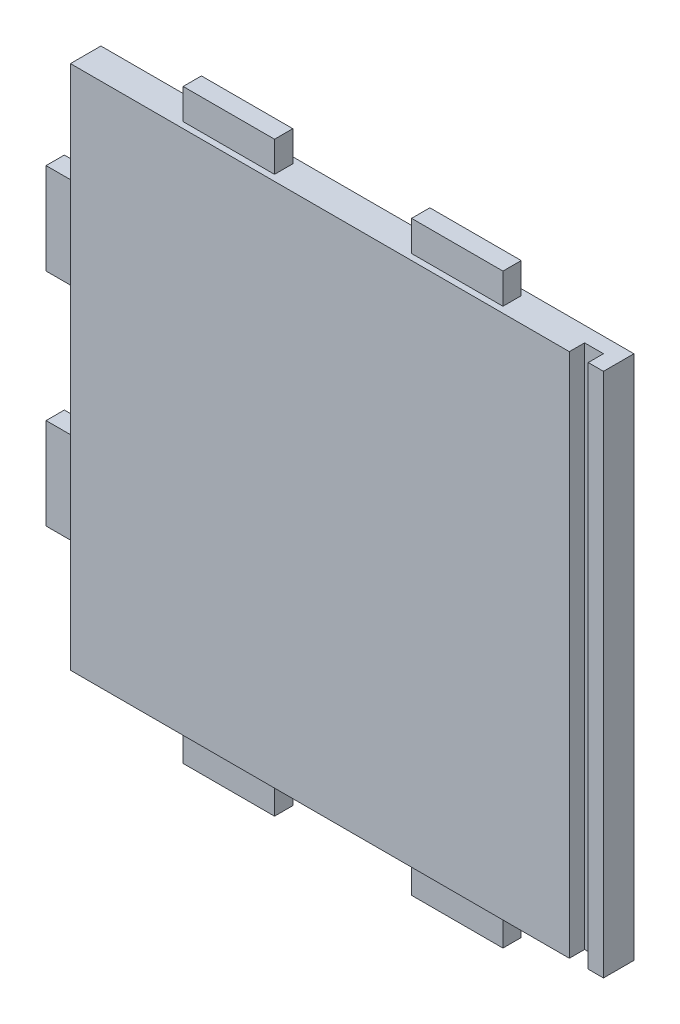
from build123d import *

# Parameters (mm, degrees)
ESBO_O1_W                = 175
ESBO_O1_H                = 172.5
RESSALTO_EXTRUS_O1_DEPTH = 10
ESBO_O5_W                = 30
ESBO_O5_H                = 6
RESSALTO_EXTRUS_O5_DEPTH = 10
ESBO_O6_W                = 6
ESBO_O6_H                = 30
RESSALTO_EXTRUS_O6_DEPTH = 10
ESBO_O7_W                = 30
ESBO_O7_H                = 6
RESSALTO_EXTRUS_O7_DEPTH = 10
ESBO_O9_W                = 6.2
ESBO_O9_H                = 172.5
CORTE_EXTRUS_O2_DEPTH    = 5
ESBO_O10_R               = 1.5
CORTE_EXTRUS_O3_DEPTH    = 8
ESBO_O11_R               = 1.5
CORTE_EXTRUS_O4_DEPTH    = 8


with BuildPart() as part:
    # Esboço1 → Ressalto-extrusão1 (new body)
    with BuildSketch(Plane.XY):
        Rectangle(ESBO_O1_W, ESBO_O1_H)
    extrude(amount=RESSALTO_EXTRUS_O1_DEPTH)

    # Esboço5 → Ressalto-extrusão5 (add)
    with BuildSketch(Plane(origin=(0, 86.25, 0), x_dir=(1, 0, 0), z_dir=(0, 1, 0))):
        with Locations((-37.5, -5)):
            Rectangle(ESBO_O5_W, ESBO_O5_H)
        with Locations((37.5, -5)):
            Rectangle(ESBO_O5_W, ESBO_O5_H)
    extrude(amount=RESSALTO_EXTRUS_O5_DEPTH)

    # Esboço6 → Ressalto-extrusão6 (add)
    with BuildSketch(Plane.ZY.offset(87.5)):
        with Locations((5, 36.25)):
            Rectangle(ESBO_O6_W, ESBO_O6_H)
        with Locations((5, -36.25)):
            Rectangle(ESBO_O6_W, ESBO_O6_H)
    extrude(amount=RESSALTO_EXTRUS_O6_DEPTH)

    # Esboço7 → Ressalto-extrusão7 (add)
    with BuildSketch(Plane.XZ.offset(86.25)):
        with Locations((-37.5, 5)):
            Rectangle(ESBO_O7_W, ESBO_O7_H)
        with Locations((37.5, 5)):
            Rectangle(ESBO_O7_W, ESBO_O7_H)
    extrude(amount=RESSALTO_EXTRUS_O7_DEPTH)

    # Esboço9 → Corte-extrusão2 (cut)
    with BuildSketch(Plane.XY.offset(10)):
        with Locations((79.4, 0)):
            Rectangle(ESBO_O9_W, ESBO_O9_H)
    extrude(amount=-CORTE_EXTRUS_O2_DEPTH, mode=Mode.SUBTRACT)

    # Esboço10 → Corte-extrusão3 (cut)
    with BuildSketch(Plane.ZY.offset(87.5)):
        with Locations((5, -71.25)):
            Circle(ESBO_O10_R)
    extrude(amount=-CORTE_EXTRUS_O3_DEPTH, mode=Mode.SUBTRACT)

    # Esboço11 → Corte-extrusão4 (cut)
    with BuildSketch(Plane.XZ.offset(86.25)):
        with Locations((65, 5)):
            Circle(ESBO_O11_R)
    extrude(amount=-CORTE_EXTRUS_O4_DEPTH, mode=Mode.SUBTRACT)


solid = part.part
